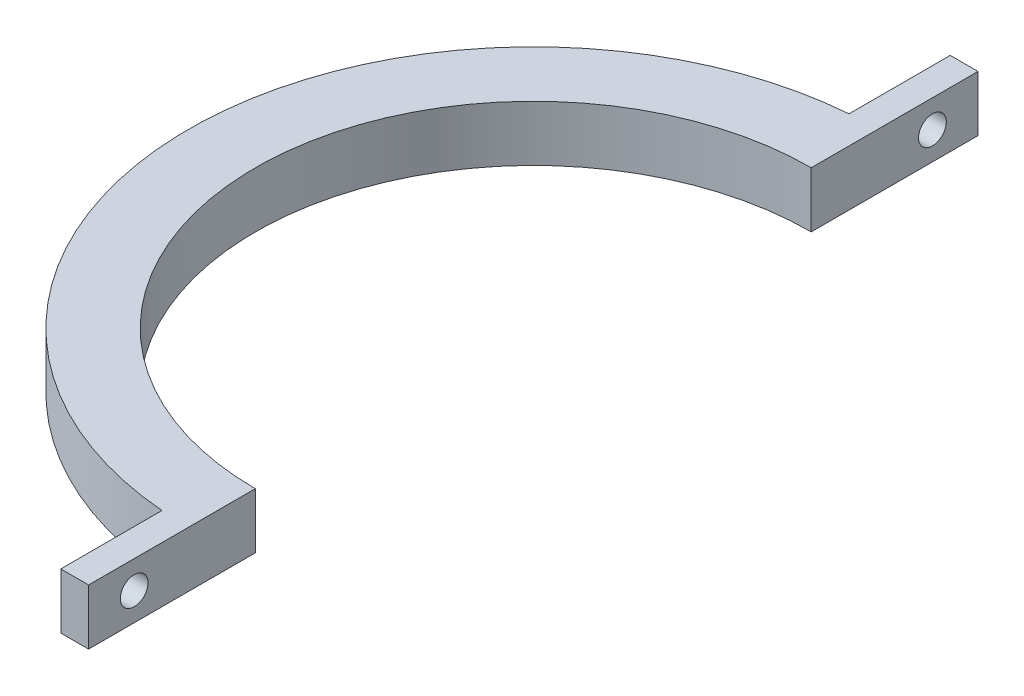
from build123d import *

# Parameters (mm, degrees)
BOSS_EXTRUDE1_DEPTH = 5
SKETCH5_R           = 1.25
CUT_EXTRUDE1_DEPTH  = 3.5


with BuildPart() as part:
    # Sketch1 → Boss-Extrude1 (new body)
    with BuildSketch(Plane(origin=(0, 0, 0), x_dir=(1, 0, 0), z_dir=(0, 1, 0))):
        with BuildLine():
            Line((-2.5, -30.899029111), (-2.5, -24.874685928))
            ThreePointArc((-2.5, -24.874685928), (-25, 0), (-2.5, 24.874685928))
            Line((-2.5, 24.874685928), (-2.5, 30.899029111))
            ThreePointArc((-2.5, 30.899029111), (-31, 0), (-2.5, -30.899029111))
        make_face()
        with BuildLine():
            Line((0, -31), (0, -25))
            ThreePointArc((0, -25), (-1.251569376, -24.968651828), (-2.5, -24.874685928))
            Line((-2.5, -24.874685928), (-2.5, -30.899029111))
            ThreePointArc((-2.5, -30.899029111), (-1.251019097, -30.974746992), (0, -31))
        make_face()
        with BuildLine():
            Line((0, -40), (0, -31))
            ThreePointArc((0, -31), (-1.251019097, -30.974746992), (-2.5, -30.899029111))
            Line((-2.5, -30.899029111), (-2.5, -40))
            Line((-2.5, -40), (0, -40))
        make_face()
        with BuildLine():
            Line((-2.5, 30.899029111), (-2.5, 24.874685928))
            ThreePointArc((-2.5, 24.874685928), (-1.251569376, 24.968651828), (0, 25))
            Line((0, 25), (0, 31))
            ThreePointArc((0, 31), (-1.251019097, 30.974746992), (-2.5, 30.899029111))
        make_face()
        with BuildLine():
            Line((-2.5, 40), (-2.5, 30.899029111))
            ThreePointArc((-2.5, 30.899029111), (-1.251019097, 30.974746992), (0, 31))
            Line((0, 31), (0, 40))
            Line((0, 40), (-2.5, 40))
        make_face()
    extrude(amount=BOSS_EXTRUDE1_DEPTH)

    # Sketch5 → Cut-Extrude1 (cut, through all)
    with BuildSketch(Plane.ZY.offset(2.5)):
        with Locations((-35.899029111, 2.5)):
            Circle(SKETCH5_R)
        with Locations((35.899029111, 2.5)):
            Circle(SKETCH5_R)
    extrude(amount=-CUT_EXTRUDE1_DEPTH, mode=Mode.SUBTRACT)


solid = part.part
